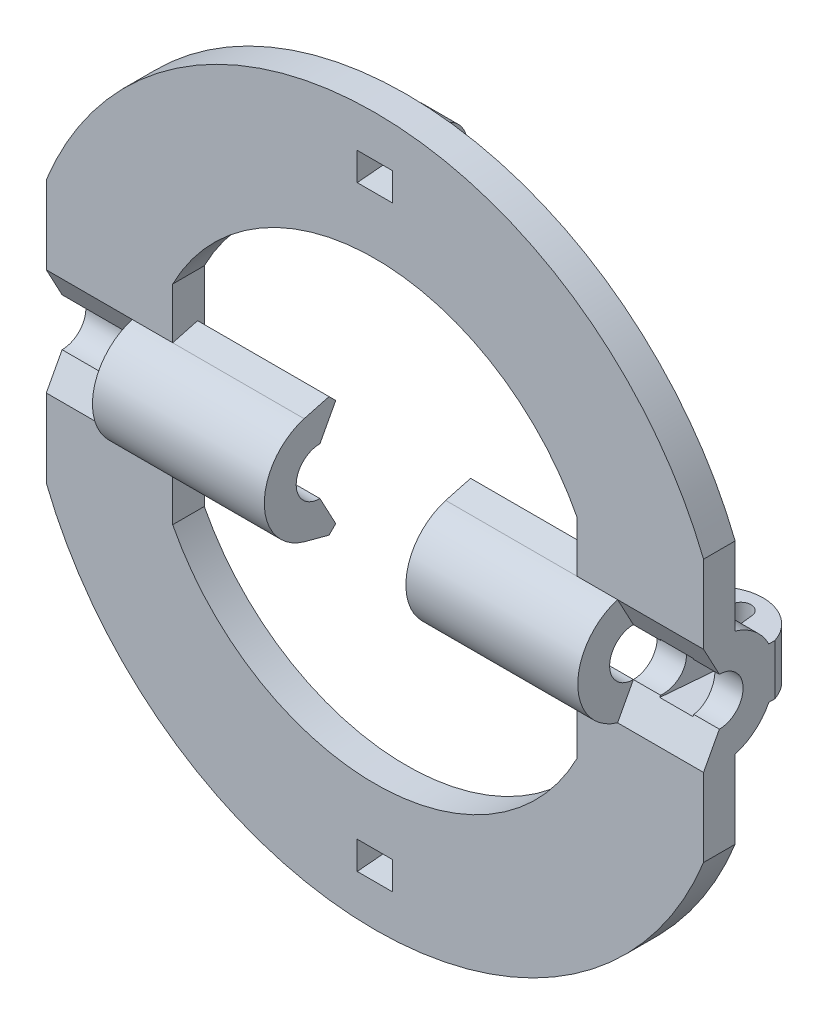
from build123d import *
from build123d.topology import SkipClean

# Parameters (mm, degrees)
BOSS_EXTRUDE1_DEPTH                           = 0.79375
BOSS_EXTRUDE1_DEPTH_BACK                      = 0.79375
SKETCH1_R                                     = 17.78
SKETCH1_R_2                                   = 11.43
SKETCH20_R                                    = 2.794
BOSS_EXTRUDE7_DEPTH                           = 6.35
CUT_FOR_SCREW_CLEARANCE_ON_SIDE_DEPTH         = 26.39938485
CUT_FOR_AXLE_DEPTH                            = 33.174893036
CUT_FOR_AXLE_DEPTH_BACK                       = 33.174893036
SKETCH22_R                                    = 1.1938
CUT1_FOR_STRAIGHT_PULL_ON_AXLE_HOLE_DEPTH     = 2.032
CUT2_FOR_STRAIGHT_PULL_ON_AXLE_HOLE_DEPTH     = 34.878306426
X_AXIS_RING_DEPTH                             = 1.27
X_AXIS_RING_DEPTH_BACK                        = 1.27
SKETCH42_R                                    = 0.508
CUT_START                                     = -2.54
CUT_FOR_STRAIGHT_PULL_ON_X_AXIS_RING_DEPTH    = 2.54
Y_AXIS_CONTROL_WIRE_RING_DEPTH                = 0.889
Y_AXIS_CONTROL_WIRE_RING_DEPTH_BACK           = 0.889
SKETCH29_R                                    = 0.508
Y_AXIS_STRAIGHT_PULL_FEATURE_DEPTH            = 1.778
Y_AXIS_STRAIGHT_PULL_FEATURE_ON_MIRRORR_DEPTH = 1.778
BUILD_OUT_MATERIAL_FOR_AXLE_HOLE_DEPTH        = 1.5875
MIRROR17_COPY_1_DEPTH                         = 1.5875
CUT_EXTRUDE1_START                            = -2.032
CUT_EXTRUDE1_DEPTH                            = 2.032
CUT_EXTRUDE2_DEPTH                            = 35.042125789
BOSS_EXTRUDE8_DEPTH                           = 6.604


with BuildPart() as part:
    # Sketch1 → Boss-Extrude1 (new, two sides: drawn at the far end of the back side and taken through both)
    with BuildSketch(Plane.XY.offset(-BOSS_EXTRUDE1_DEPTH_BACK)):
        Circle(SKETCH1_R)
        Circle(SKETCH1_R_2, mode=Mode.SUBTRACT)
    extrude(amount=BOSS_EXTRUDE1_DEPTH + BOSS_EXTRUDE1_DEPTH_BACK)

    # Sketch20 → Boss-Extrude7 (add)
    with BuildSketch(Plane(origin=(10.16, 0, 0), x_dir=(0, 0, -1), z_dir=(1, 0, 0))):
        Circle(SKETCH20_R)
    boss_extrude7 = extrude(amount=BOSS_EXTRUDE7_DEPTH)

    # Sketch21 → cut for screw clearance on side (cut, through all)
    with BuildSketch(Plane.XY.offset(0.79375)):
        Polygon((16.51, 0), (16.51, 6.599113577), (17.78, 6.599113577), (17.78, 0), (17.78, -6.599113577), (16.51, -6.599113577), align=None)
    cut_for_screw_clearance_on_side = extrude(amount=-CUT_FOR_SCREW_CLEARANCE_ON_SIDE_DEPTH, mode=Mode.SUBTRACT)

    # Mirror1: Boss-Extrude7, cut for screw clearance on side across plane
    add(boss_extrude7.mirror(Plane(origin=(0, 0, 0), x_dir=(0, 0, 1), z_dir=(1, 0, 0))))
    add(cut_for_screw_clearance_on_side.mirror(Plane(origin=(0, 0, 0), x_dir=(0, 0, 1), z_dir=(1, 0, 0))), mode=Mode.SUBTRACT)

    # Sketch22 → cut for axle (cut, two sides: drawn at the far end of the back side and taken through both)
    with BuildSketch(Plane(origin=(10.16, 0, 0), x_dir=(0, 0, -1), z_dir=(1, 0, 0)).offset(-CUT_FOR_AXLE_DEPTH_BACK)):
        Circle(SKETCH22_R)
    extrude(amount=CUT_FOR_AXLE_DEPTH + CUT_FOR_AXLE_DEPTH_BACK, mode=Mode.SUBTRACT)

    # Sketch35 → cut1 for straight pull on axle hole (cut)
    with BuildSketch(Plane.ZY.offset(-10.16)):
        with BuildLine():
            Line((0, 1.1938), (-0.79375, 2.678879792))
            Line((-0.79375, 2.678879792), (-3.088550318, 2.678879792))
            Line((-3.088550318, 2.678879792), (-3.088550318, -2.678879792))
            Line((-3.088550318, -2.678879792), (-0.79375, -2.678879792))
            Line((-0.79375, -2.678879792), (0, -1.1938))
            ThreePointArc((0, -1.1938), (1.1938, 0), (0, 1.1938))
        make_face()
    extrude(amount=-CUT1_FOR_STRAIGHT_PULL_ON_AXLE_HOLE_DEPTH, mode=Mode.SUBTRACT)

    # Sketch41 → cut2 for straight pull on axle hole (cut, through all)
    with BuildSketch(Plane.ZY.offset(-12.192)):
        with BuildLine():
            Line((0, 1.1938), (0.79375, 2.678879792))
            Line((0.79375, 2.678879792), (3.158535805, 2.885771741))
            Line((3.158535805, 2.885771741), (3.158535805, -2.885771741))
            Line((3.158535805, -2.885771741), (0.79375, -2.678879792))
            Line((0.79375, -2.678879792), (0, -1.1938))
            ThreePointArc((0, -1.1938), (-1.1938, 0), (0, 1.1938))
        make_face()
    extrude(amount=-CUT2_FOR_STRAIGHT_PULL_ON_AXLE_HOLE_DEPTH, mode=Mode.SUBTRACT)

    # Sketch42 → x axis ring (add, two sides: drawn at the far end of the back side and taken through both)
    with BuildSketch(Plane(origin=(0, 0, 0), x_dir=(1, 0, 0), z_dir=(0, 1, 0)).offset(-X_AXIS_RING_DEPTH_BACK)):
        with BuildLine():
            Line((12.192, 2.794), (12.192, 2.392482279))
            Line((12.192, 2.392482279), (16.51, 2.392482279))
            Line((16.51, 2.392482279), (16.51, 2.794))
            ThreePointArc((16.51, 2.794), (14.351, 4.351221008), (12.192, 2.794))
        make_face()
        with Locations((14.351, 3.242227956)):
            Circle(SKETCH42_R, mode=Mode.SUBTRACT)
    extrude(amount=X_AXIS_RING_DEPTH + X_AXIS_RING_DEPTH_BACK)

    # Sketch43 → cut for straight pull on x axis ring (cut)
    with BuildSketch(Plane(origin=(0, 1.27, 0), x_dir=(1, 0, 0), z_dir=(0, 1, 0)).offset(CUT_START)):
        with BuildLine():
            Line((13.843, 3.242227956), (13.489897683, -0.79375))
            Line((13.489897683, -0.79375), (15.315854335, -0.79375))
            Line((15.315854335, -0.79375), (14.859, 3.242227956))
            ThreePointArc((14.859, 3.242227956), (14.351, 3.750227956), (13.843, 3.242227956))
        make_face()
    extrude(amount=CUT_FOR_STRAIGHT_PULL_ON_X_AXIS_RING_DEPTH, mode=Mode.SUBTRACT)


with BuildPart() as body_2:
    # Sketch29 → y axis control wire ring (new, two sides: drawn at the far end of the back side and taken through both)
    with BuildSketch(Plane(origin=(0, 0, 0), x_dir=(0, 0, -1), z_dir=(1, 0, 0)).offset(-Y_AXIS_CONTROL_WIRE_RING_DEPTH_BACK)):
        with BuildLine():
            Line((0.79375, 16.51), (1.42875, 16.51))
            ThreePointArc((1.42875, 16.51), (2.95275, 14.986), (1.42875, 13.462))
            Line((1.42875, 13.462), (0.795532055, 13.462))
            Line((0.795532055, 13.462), (0.79375, 16.51))
        make_face()
        with Locations((1.42875, 14.986)):
            Circle(SKETCH29_R, mode=Mode.SUBTRACT)
    extrude(amount=Y_AXIS_CONTROL_WIRE_RING_DEPTH + Y_AXIS_CONTROL_WIRE_RING_DEPTH_BACK)


with BuildPart() as y_axis_straight_pull_feature_tool:
    # Sketch30 → y axis straight pull feature (new body)
    with BuildSketch(Plane(origin=(0.889, 0, 0), x_dir=(0, 0, -1), z_dir=(1, 0, 0))):
        with BuildLine():
            Line((1.42875, 15.494), (-0.79375, 15.688443555))
            Line((-0.79375, 15.688443555), (-0.79375, 14.283556445))
            Line((-0.79375, 14.283556445), (1.42875, 14.478))
            ThreePointArc((1.42875, 14.478), (1.93675, 14.986), (1.42875, 15.494))
        make_face()
    extrude(amount=-Y_AXIS_STRAIGHT_PULL_FEATURE_DEPTH)


with BuildPart() as part_1:
    add(part.part)

    # y axis straight pull feature: cut by y_axis_straight_pull_feature_tool
    add(y_axis_straight_pull_feature_tool.part, mode=Mode.SUBTRACT)

    # Sketch31 → y axis straight pull feature on mirrorr (cut)
    with BuildSketch(Plane(origin=(0.889, 0, 0), x_dir=(0, 0, -1), z_dir=(1, 0, 0))):
        with BuildLine():
            Line((1.42875, -14.478), (-0.79375, -14.283556445))
            Line((-0.79375, -14.283556445), (-0.79375, -15.688443555))
            Line((-0.79375, -15.688443555), (1.42875, -15.494))
            ThreePointArc((1.42875, -15.494), (1.93675, -14.986), (1.42875, -14.478))
        make_face()
    extrude(amount=-Y_AXIS_STRAIGHT_PULL_FEATURE_ON_MIRRORR_DEPTH, mode=Mode.SUBTRACT)

    # Sketch40 → build out material for axle hole (add)
    with BuildSketch(Plane.XY.offset(0.79375)):
        Polygon((10.16, 5.249781847), (10.16, 2.678879792), (11.111638181, 2.678879792), (10.736884246, 4.372121259), align=None)
    build_out_material_for_axle_hole = extrude(amount=-BUILD_OUT_MATERIAL_FOR_AXLE_HOLE_DEPTH)

    # Mirror16: build out material for axle hole across plane
    add(build_out_material_for_axle_hole.mirror(Plane.ZX))

    # Mirror17: build out material for axle hole across plane
    add(build_out_material_for_axle_hole.mirror(Plane(origin=(0, 0, 0), x_dir=(0, 0, 1), z_dir=(1, 0, 0))))

    # Mirror17 copy 1 sketch → Mirror17 copy 1 (add)
    with BuildSketch(Plane(origin=(0, 0, 0.79375), x_dir=(-1, 0, 0), z_dir=(0, 0, 1))):
        Polygon((10.16, 5.249781847), (10.16, 2.678879792), (11.111638181, 2.678879792), (10.736884246, 4.372121259), align=None)
    extrude(amount=-MIRROR17_COPY_1_DEPTH)

    # Sketch44 → Cut-Extrude1 (cut)
    with SkipClean():  # the faces are left unmerged after this step: merging them gives an invalid solid
        with BuildSketch(Plane(origin=(-10.16, 0, 0), x_dir=(0, 0, -1), z_dir=(1, 0, 0)).offset(CUT_EXTRUDE1_START)):
            with BuildLine():
                Line((0, 1.1938), (0.79375, 2.678879792))
                Line((0.79375, 2.678879792), (4.74590947, 2.678879792))
                Line((4.74590947, 2.678879792), (4.74590947, -2.678879792))
                Line((4.74590947, -2.678879792), (0.79375, -2.678879792))
                Line((0.79375, -2.678879792), (0, -1.1938))
                ThreePointArc((0, -1.1938), (-1.1938, 0), (0, 1.1938))
            make_face()
        extrude(amount=CUT_EXTRUDE1_DEPTH, mode=Mode.SUBTRACT)

    # Sketch45 → Cut-Extrude2 (cut, through all)
    with BuildSketch(Plane(origin=(-12.192, 0, 0), x_dir=(0, 0, -1), z_dir=(1, 0, 0))):
        with BuildLine():
            Line((0, 1.1938), (-0.79375, 2.678879792))
            Line((-0.79375, 2.678879792), (-3.136476286, 2.678879792))
            Line((-3.136476286, 2.678879792), (-3.136476286, -2.678879792))
            Line((-3.136476286, -2.678879792), (-0.79375, -2.678879792))
            Line((-0.79375, -2.678879792), (0, -1.1938))
            ThreePointArc((0, -1.1938), (1.1938, 0), (0, 1.1938))
        make_face()
    extrude(amount=-CUT_EXTRUDE2_DEPTH, mode=Mode.SUBTRACT)

    # Sketch46 → Boss-Extrude8 (add)
    with BuildSketch(Plane(origin=(-10.16, 0, 0), x_dir=(0, 0, -1), z_dir=(1, 0, 0))):
        with BuildLine():
            Line((0.79375, 2.678879792), (0.458271776, 3.014358015))
            Line((0.458271776, 3.014358015), (-0.79375, 2.678879792))
            ThreePointArc((-0.79375, 2.678879792), (-2.794, 0), (-0.79375, -2.678879792))
            Line((-0.79375, -2.678879792), (0.458271776, -3.014358015))
            Line((0.458271776, -3.014358015), (0.79375, -2.678879792))
            Line((0.79375, -2.678879792), (0, -1.1938))
            ThreePointArc((0, -1.1938), (-1.1938, 0), (0, 1.1938))
            Line((0, 1.1938), (0.79375, 2.678879792))
        make_face()
    boss_extrude8 = extrude(amount=BOSS_EXTRUDE8_DEPTH)

    # Mirror19: Boss-Extrude8 across plane
    add(boss_extrude8.mirror(Plane(origin=(0, 0, 0), x_dir=(0, 0, 1), z_dir=(1, 0, 0))))


with BuildPart() as body_2_1:
    add(body_2.part)

    # y axis straight pull feature: cut by y_axis_straight_pull_feature_tool
    add(y_axis_straight_pull_feature_tool.part, mode=Mode.SUBTRACT)


with BuildPart() as body_3:
    # mirror of y ring: mirrored copy
    add(body_2_1.part.mirror(Plane.ZX))


solid = Compound([part_1.part, body_2_1.part, body_3.part])
